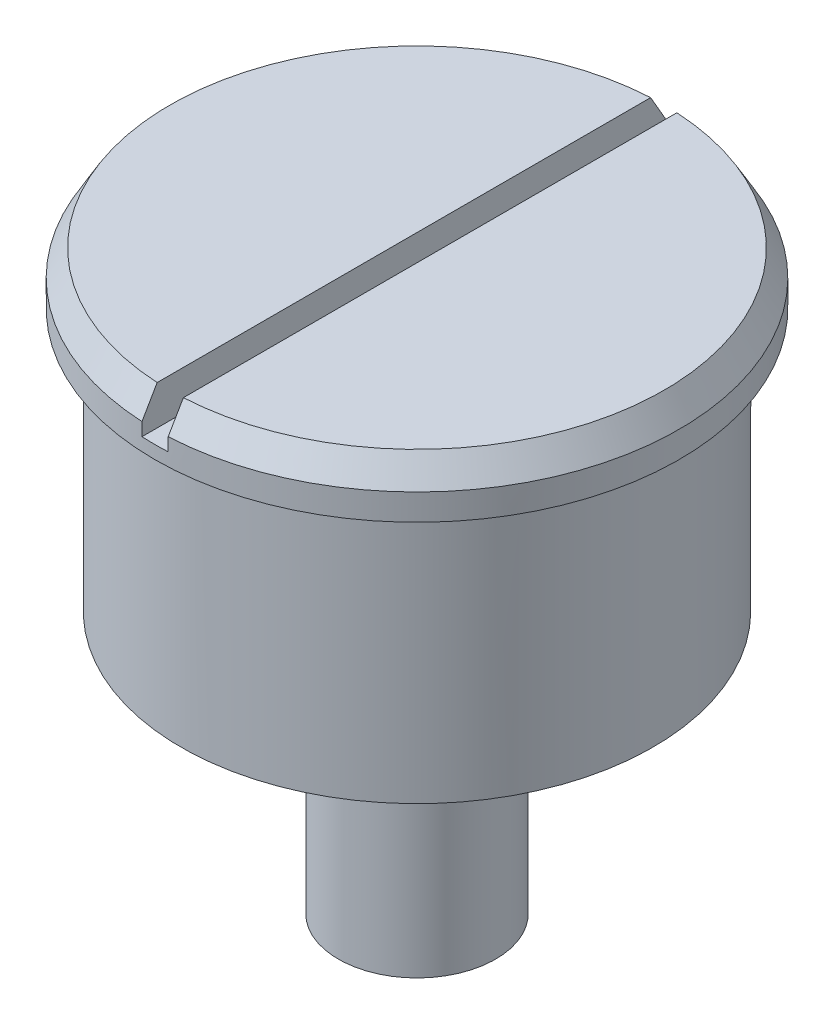
from build123d import *

# Parameters (mm, degrees)
CROQUIS1_R                 = 4.5
SALIENTE_EXTRUIR1_DEPTH    = 4
CROQUIS2_R                 = 5
SALIENTE_EXTRUIR2_DEPTH    = 1
CROQUIS3_W                 = 0.5
CROQUIS3_H                 = 4.167915925
CORTAR_EXTRUIR1_DEPTH      = 6
CORTAR_EXTRUIR1_DEPTH_BACK = 6
CHAFL_N1_SIZE              = 0.5
CHAFL_N1_SIZE2             = 0.288675135
CROQUIS4_R                 = 4.5
SALIENTE_EXTRUIR3_DEPTH    = 1
CROQUIS5_R                 = 1.5
SALIENTE_EXTRUIR4_DEPTH    = 5


with BuildPart() as part:
    # Croquis1 → Saliente-Extruir1 (new body)
    with BuildSketch(Plane(origin=(0, 0, 0), x_dir=(1, 0, 0), z_dir=(0, 1, 0))):
        Circle(CROQUIS1_R)
    extrude(amount=SALIENTE_EXTRUIR1_DEPTH)

    # Croquis2 → Saliente-Extruir2 (add)
    with BuildSketch(Plane(origin=(0, 4, 0), x_dir=(1, 0, 0), z_dir=(0, 1, 0))):
        Circle(CROQUIS2_R)
    extrude(amount=SALIENTE_EXTRUIR2_DEPTH)

    # Croquis3 → Cortar-Extruir1 (cut, two sides)
    with BuildSketch(Plane.XY) as cortar_extruir1_sk:
        with Locations((0, 6.333957963)):
            Rectangle(CROQUIS3_W, CROQUIS3_H)
    extrude(amount=CORTAR_EXTRUIR1_DEPTH, mode=Mode.SUBTRACT)
    extrude(cortar_extruir1_sk.sketch, amount=-CORTAR_EXTRUIR1_DEPTH_BACK, mode=Mode.SUBTRACT)

    # Chaflán1
    chafl_n1_edges = [part.edges().sort_by_distance(p)[0] for p in [
        (-5, 5, 0),
        (3.622844187, 5, 3.446012188),
    ]]
    chafl_n1_side = [part.faces().sort_by_distance(p)[0] for p in [
        (-5, 4.5, 0),
    ]]
    chamfer(chafl_n1_edges, length=CHAFL_N1_SIZE, length2=CHAFL_N1_SIZE2, reference=chafl_n1_side[0])

    # Croquis4 → Saliente-Extruir3 (add)
    with BuildSketch(Plane.XZ):
        Circle(CROQUIS4_R)
    extrude(amount=SALIENTE_EXTRUIR3_DEPTH)

    # Croquis5 → Saliente-Extruir4 (add)
    with BuildSketch(Plane(origin=(0, -1, 0), x_dir=(-1, 0, 0), z_dir=(0, -1, 0))):
        Circle(CROQUIS5_R)
    extrude(amount=SALIENTE_EXTRUIR4_DEPTH)


solid = part.part
